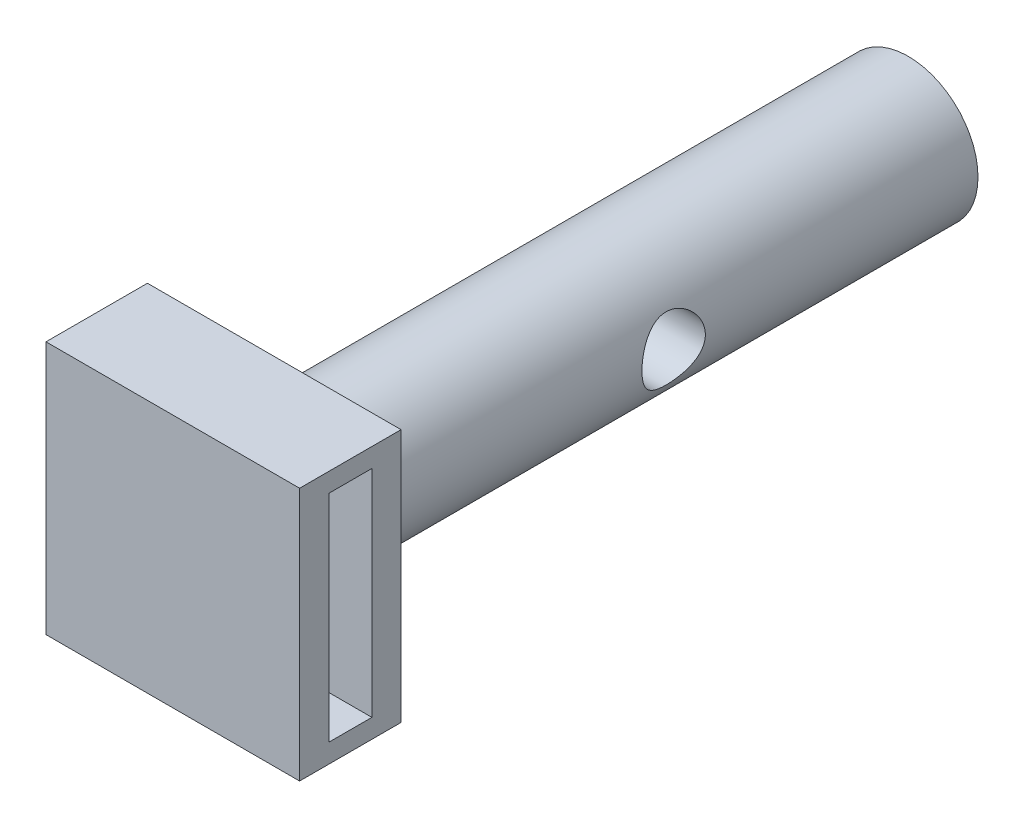
from build123d import *

# Parameters (mm, degrees)
SKETCH2_R               = 2.75
SKETCH3_R               = 2.75
SKETCH3_7_W             = 10
SKETCH3_7_H             = 10
BOSS_EXTRUDE4_DEPTH     = 4
CUT_EXTRUDE2_DEPTH      = 32.080540536
CUT_EXTRUDE2_DEPTH_BACK = 32.080540536
SKETCH8_W               = 1.7
SKETCH8_H               = 8.5
FILLET1_R               = 1
CUT_EXTRUDE4_DEPTH      = 30.849623113
CUT_EXTRUDE4_DEPTH_BACK = 30.849623113
SKETCH11_R              = 1.25


with BuildPart() as part:
    # Sketch2 → Loft1 section 0
    with BuildSketch(Plane.XY):
        Circle(SKETCH2_R)
    # Sketch3 → Loft1 section 1
    with BuildSketch(Plane.XY.offset(25)):
        Circle(SKETCH3_R)
    loft()

    # Sketch3_7 → Boss-Extrude4 (add)
    with BuildSketch(Plane.XY.offset(25)):
        Rectangle(SKETCH3_7_W, SKETCH3_7_H)
    extrude(amount=BOSS_EXTRUDE4_DEPTH)

    # Sketch8 → Cut-Extrude2 (cut, two sides: drawn at the far end of the back side and taken through both)
    with BuildSketch(Plane(origin=(5, 0, 0), x_dir=(0, 0, -1), z_dir=(1, 0, 0)).offset(-CUT_EXTRUDE2_DEPTH_BACK)):
        with Locations((-27, 0)):
            Rectangle(SKETCH8_W, SKETCH8_H)
    extrude(amount=CUT_EXTRUDE2_DEPTH + CUT_EXTRUDE2_DEPTH_BACK, mode=Mode.SUBTRACT)

    # Fillet1
    fillet1_edges = [part.edges().sort_by_distance(p)[0] for p in [
        (-2.75, 0, 25),
    ]]
    fillet(fillet1_edges, radius=FILLET1_R)

    # Sketch11 → Cut-Extrude4 (cut, two sides: drawn at the far end of the back side and taken through both)
    with BuildSketch(Plane(origin=(0, 0, 0), x_dir=(0, 0, -1), z_dir=(1, 0, 0)).offset(-CUT_EXTRUDE4_DEPTH_BACK)):
        with Locations((-12, 0)):
            Circle(SKETCH11_R)
    extrude(amount=CUT_EXTRUDE4_DEPTH + CUT_EXTRUDE4_DEPTH_BACK, mode=Mode.SUBTRACT)


solid = part.part
